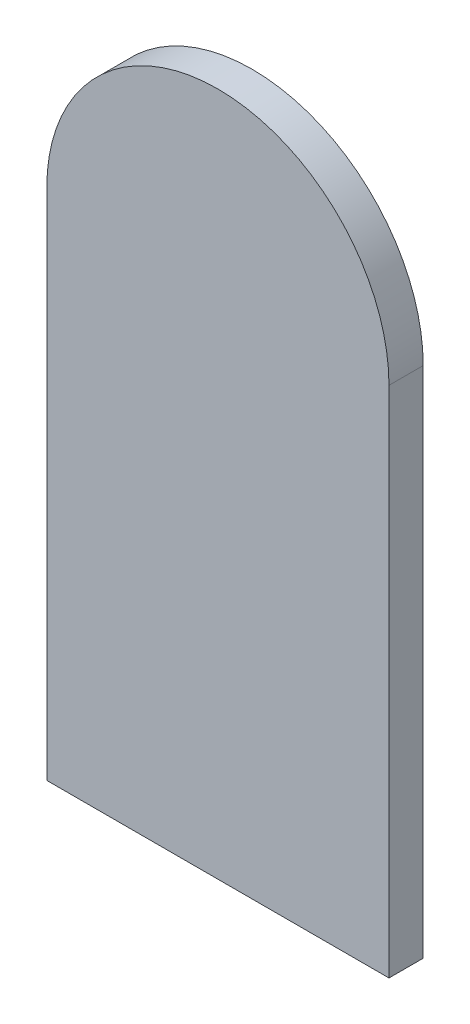
from build123d import *

# Parameters (mm, degrees)
BOSS_EXTRU_1_DEPTH = 2


with BuildPart() as part:
    # Esquisse1 → Boss.-Extru.1 (new body)
    with BuildSketch(Plane.XY):
        with BuildLine():
            Line((-10, 0), (-10, 30))
            ThreePointArc((-10, 30), (0, 40), (10, 30))
            Line((10, 30), (10, 0))
            Line((10, 0), (-10, 0))
        make_face()
    extrude(amount=BOSS_EXTRU_1_DEPTH)


solid = part.part
